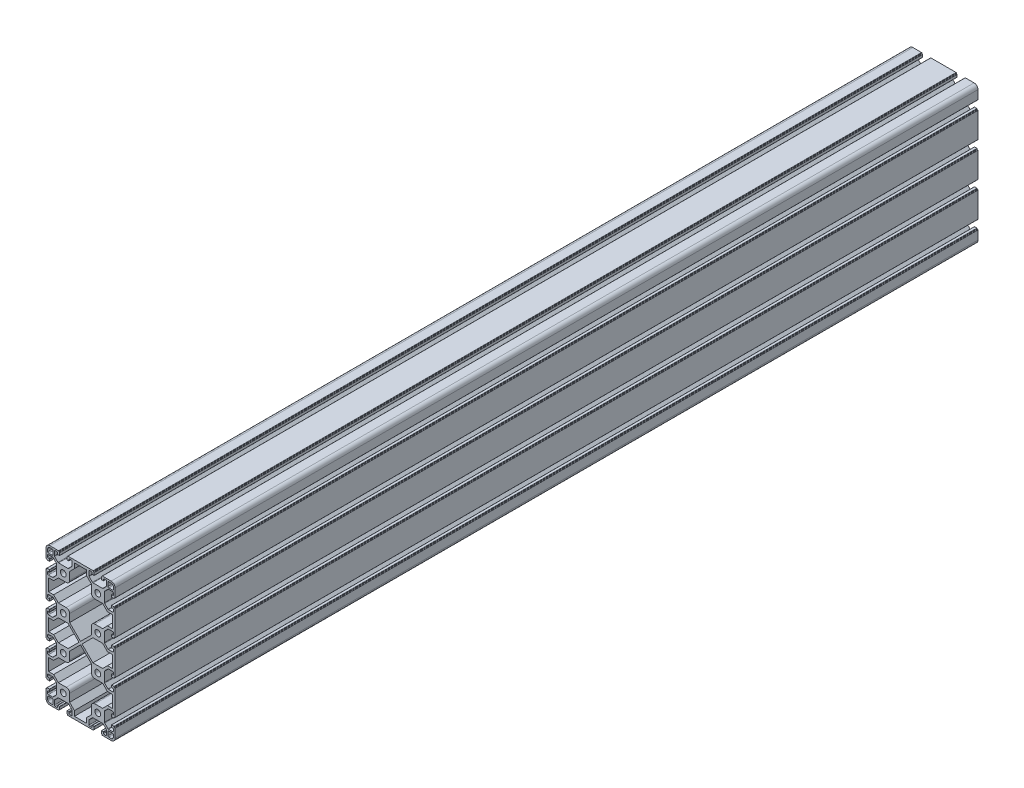
from build123d import *

# Parameters (mm, degrees)
SKETCH_1_R      = 3.4
EXTRUDE_1_DEPTH = 1000


with BuildPart() as part:
    # Эскиз1 → Бобышка-Вытянуть1 (new body)
    with BuildSketch(Plane.XY):
        with BuildLine():
            Line((-20, 10.25), (-20, 15.5))
            ThreePointArc((-20, 15.5), (-18.681980515, 18.681980515), (-15.5, 20))
            Line((-15.5, 20), (-10.25, 20))
            Line((-10.25, 20), (-5.4, 20))
            ThreePointArc((-5.4, 20), (-5.187867966, 19.912132034), (-5.1, 19.7))
            Line((-5.1, 19.7), (-5.1, 19.3))
            ThreePointArc((-5.1, 19.3), (-5.012132034, 19.087867966), (-4.8, 19))
            Line((-4.8, 19), (-4.4, 19))
            ThreePointArc((-4.4, 19), (-4.187867966, 18.912132034), (-4.1, 18.7))
            Line((-4.1, 18.7), (-4.1, 16))
            ThreePointArc((-4.1, 16), (-4.187867966, 15.787867966), (-4.4, 15.7))
            Line((-4.4, 15.7), (-6.3, 15.7))
            ThreePointArc((-6.3, 15.7), (-6.512132034, 15.787867966), (-6.6, 16))
            Line((-6.6, 16), (-6.6, 17.2))
            ThreePointArc((-6.6, 17.2), (-6.892893219, 17.907106781), (-7.6, 18.2))
            Line((-7.6, 18.2), (-9.25, 18.2))
            ThreePointArc((-9.25, 18.2), (-9.957106781, 17.907106781), (-10.25, 17.2))
            Line((-10.25, 17.2), (-10.25, 12.464213562))
            ThreePointArc((-10.25, 12.464213562), (-10.173879533, 12.08153013), (-9.957106781, 11.757106781))
            Line((-9.957106781, 11.757106781), (-6.192893219, 7.992893219))
            ThreePointArc((-6.192893219, 7.992893219), (-5.86846987, 7.776120467), (-5.485786438, 7.7))
            Line((-5.485786438, 7.7), (5.485786438, 7.7))
            ThreePointArc((5.485786438, 7.7), (5.86846987, 7.776120467), (6.192893219, 7.992893219))
            Line((6.192893219, 7.992893219), (9.957106781, 11.757106781))
            ThreePointArc((9.957106781, 11.757106781), (10.173879533, 12.08153013), (10.25, 12.464213562))
            Line((10.25, 12.464213562), (10.25, 17.2))
            ThreePointArc((10.25, 17.2), (9.957106781, 17.907106781), (9.25, 18.2))
            Line((9.25, 18.2), (7.6, 18.2))
            ThreePointArc((7.6, 18.2), (6.892893219, 17.907106781), (6.6, 17.2))
            Line((6.6, 17.2), (6.6, 16))
            ThreePointArc((6.6, 16), (6.512132034, 15.787867966), (6.3, 15.7))
            Line((6.3, 15.7), (4.4, 15.7))
            ThreePointArc((4.4, 15.7), (4.187867966, 15.787867966), (4.1, 16))
            Line((4.1, 16), (4.1, 18.7))
            ThreePointArc((4.1, 18.7), (4.187867966, 18.912132034), (4.4, 19))
            Line((4.4, 19), (4.8, 19))
            ThreePointArc((4.8, 19), (5.012132034, 19.087867966), (5.1, 19.3))
            Line((5.1, 19.3), (5.1, 19.7))
            ThreePointArc((5.1, 19.7), (5.187867966, 19.912132034), (5.4, 20))
            Line((5.4, 20), (10.25, 20))
            Line((10.25, 20), (29.75, 20))
            Line((29.75, 20), (34.6, 20))
            ThreePointArc((34.6, 20), (34.812132034, 19.912132034), (34.9, 19.7))
            Line((34.9, 19.7), (34.9, 19.3))
            ThreePointArc((34.9, 19.3), (34.987867966, 19.087867966), (35.2, 19))
            Line((35.2, 19), (35.6, 19))
            ThreePointArc((35.6, 19), (35.812132034, 18.912132034), (35.9, 18.7))
            Line((35.9, 18.7), (35.9, 16))
            ThreePointArc((35.9, 16), (35.812132034, 15.787867966), (35.6, 15.7))
            Line((35.6, 15.7), (33.7, 15.7))
            ThreePointArc((33.7, 15.7), (33.487867966, 15.787867966), (33.4, 16))
            Line((33.4, 16), (33.4, 17.2))
            ThreePointArc((33.4, 17.2), (33.107106781, 17.907106781), (32.4, 18.2))
            Line((32.4, 18.2), (30.75, 18.2))
            ThreePointArc((30.75, 18.2), (30.042893219, 17.907106781), (29.75, 17.2))
            Line((29.75, 17.2), (29.75, 12.464213562))
            ThreePointArc((29.75, 12.464213562), (29.826120467, 12.08153013), (30.042893219, 11.757106781))
            Line((30.042893219, 11.757106781), (33.807106781, 7.992893219))
            ThreePointArc((33.807106781, 7.992893219), (34.13153013, 7.776120467), (34.514213562, 7.7))
            Line((34.514213562, 7.7), (45.485786438, 7.7))
            ThreePointArc((45.485786438, 7.7), (45.86846987, 7.776120467), (46.192893219, 7.992893219))
            Line((46.192893219, 7.992893219), (49.957106781, 11.757106781))
            ThreePointArc((49.957106781, 11.757106781), (50.173879533, 12.08153013), (50.25, 12.464213562))
            Line((50.25, 12.464213562), (50.25, 17.2))
            ThreePointArc((50.25, 17.2), (49.957106781, 17.907106781), (49.25, 18.2))
            Line((49.25, 18.2), (47.6, 18.2))
            ThreePointArc((47.6, 18.2), (46.892893219, 17.907106781), (46.6, 17.2))
            Line((46.6, 17.2), (46.6, 16))
            ThreePointArc((46.6, 16), (46.512132034, 15.787867966), (46.3, 15.7))
            Line((46.3, 15.7), (44.4, 15.7))
            ThreePointArc((44.4, 15.7), (44.187867966, 15.787867966), (44.1, 16))
            Line((44.1, 16), (44.1, 18.7))
            ThreePointArc((44.1, 18.7), (44.187867966, 18.912132034), (44.4, 19))
            Line((44.4, 19), (44.8, 19))
            ThreePointArc((44.8, 19), (45.012132034, 19.087867966), (45.1, 19.3))
            Line((45.1, 19.3), (45.1, 19.7))
            ThreePointArc((45.1, 19.7), (45.187867966, 19.912132034), (45.4, 20))
            Line((45.4, 20), (50.25, 20))
            Line((50.25, 20), (55.5, 20))
            ThreePointArc((55.5, 20), (58.681980515, 18.681980515), (60, 15.5))
            Line((60, 15.5), (60, 10.25))
            Line((60, 10.25), (60, 5.4))
            ThreePointArc((60, 5.4), (59.912132034, 5.187867966), (59.7, 5.1))
            Line((59.7, 5.1), (59.3, 5.1))
            ThreePointArc((59.3, 5.1), (59.087867966, 5.012132034), (59, 4.8))
            Line((59, 4.8), (59, 4.4))
            ThreePointArc((59, 4.4), (58.912132034, 4.187867966), (58.7, 4.1))
            Line((58.7, 4.1), (56, 4.1))
            ThreePointArc((56, 4.1), (55.787867966, 4.187867966), (55.7, 4.4))
            Line((55.7, 4.4), (55.7, 6.3))
            ThreePointArc((55.7, 6.3), (55.787867966, 6.512132034), (56, 6.6))
            Line((56, 6.6), (57.2, 6.6))
            ThreePointArc((57.2, 6.6), (57.907106781, 6.892893219), (58.2, 7.6))
            Line((58.2, 7.6), (58.2, 9.25))
            ThreePointArc((58.2, 9.25), (57.907106781, 9.957106781), (57.2, 10.25))
            Line((57.2, 10.25), (52.464213562, 10.25))
            ThreePointArc((52.464213562, 10.25), (52.08153013, 10.173879533), (51.757106781, 9.957106781))
            Line((51.757106781, 9.957106781), (47.992893219, 6.192893219))
            ThreePointArc((47.992893219, 6.192893219), (47.776120467, 5.86846987), (47.7, 5.485786438))
            Line((47.7, 5.485786438), (47.7, -5.485786438))
            ThreePointArc((47.7, -5.485786438), (47.776120467, -5.86846987), (47.992893219, -6.192893219))
            Line((47.992893219, -6.192893219), (51.757106781, -9.957106781))
            ThreePointArc((51.757106781, -9.957106781), (52.08153013, -10.173879533), (52.464213562, -10.25))
            Line((52.464213562, -10.25), (57.2, -10.25))
            ThreePointArc((57.2, -10.25), (57.907106781, -9.957106781), (58.2, -9.25))
            Line((58.2, -9.25), (58.2, -7.6))
            ThreePointArc((58.2, -7.6), (57.907106781, -6.892893219), (57.2, -6.6))
            Line((57.2, -6.6), (56, -6.6))
            ThreePointArc((56, -6.6), (55.787867966, -6.512132034), (55.7, -6.3))
            Line((55.7, -6.3), (55.7, -4.4))
            ThreePointArc((55.7, -4.4), (55.787867966, -4.187867966), (56, -4.1))
            Line((56, -4.1), (58.7, -4.1))
            ThreePointArc((58.7, -4.1), (58.912132034, -4.187867966), (59, -4.4))
            Line((59, -4.4), (59, -4.8))
            ThreePointArc((59, -4.8), (59.087867966, -5.012132034), (59.3, -5.1))
            Line((59.3, -5.1), (59.7, -5.1))
            ThreePointArc((59.7, -5.1), (59.912132034, -5.187867966), (60, -5.4))
            Line((60, -5.4), (60, -10.25))
            Line((60, -10.25), (60, -29.75))
            Line((60, -29.75), (60, -34.6))
            ThreePointArc((60, -34.6), (59.912132034, -34.812132034), (59.7, -34.9))
            Line((59.7, -34.9), (59.3, -34.9))
            ThreePointArc((59.3, -34.9), (59.087867966, -34.987867966), (59, -35.2))
            Line((59, -35.2), (59, -35.6))
            ThreePointArc((59, -35.6), (58.912132034, -35.812132034), (58.7, -35.9))
            Line((58.7, -35.9), (56, -35.9))
            ThreePointArc((56, -35.9), (55.787867966, -35.812132034), (55.7, -35.6))
            Line((55.7, -35.6), (55.7, -33.7))
            ThreePointArc((55.7, -33.7), (55.787867966, -33.487867966), (56, -33.4))
            Line((56, -33.4), (57.2, -33.4))
            ThreePointArc((57.2, -33.4), (57.907106781, -33.107106781), (58.2, -32.4))
            Line((58.2, -32.4), (58.2, -30.75))
            ThreePointArc((58.2, -30.75), (57.907106781, -30.042893219), (57.2, -29.75))
            Line((57.2, -29.75), (52.464213562, -29.75))
            ThreePointArc((52.464213562, -29.75), (52.08153013, -29.826120467), (51.757106781, -30.042893219))
            Line((51.757106781, -30.042893219), (47.992893219, -33.807106781))
            ThreePointArc((47.992893219, -33.807106781), (47.776120467, -34.13153013), (47.7, -34.514213562))
            Line((47.7, -34.514213562), (47.7, -45.485786438))
            ThreePointArc((47.7, -45.485786438), (47.776120467, -45.86846987), (47.992893219, -46.192893219))
            Line((47.992893219, -46.192893219), (51.757106781, -49.957106781))
            ThreePointArc((51.757106781, -49.957106781), (52.08153013, -50.173879533), (52.464213562, -50.25))
            Line((52.464213562, -50.25), (57.2, -50.25))
            ThreePointArc((57.2, -50.25), (57.907106781, -49.957106781), (58.2, -49.25))
            Line((58.2, -49.25), (58.2, -47.6))
            ThreePointArc((58.2, -47.6), (57.907106781, -46.892893219), (57.2, -46.6))
            Line((57.2, -46.6), (56, -46.6))
            ThreePointArc((56, -46.6), (55.787867966, -46.512132034), (55.7, -46.3))
            Line((55.7, -46.3), (55.7, -44.4))
            ThreePointArc((55.7, -44.4), (55.787867966, -44.187867966), (56, -44.1))
            Line((56, -44.1), (58.7, -44.1))
            ThreePointArc((58.7, -44.1), (58.912132034, -44.187867966), (59, -44.4))
            Line((59, -44.4), (59, -44.8))
            ThreePointArc((59, -44.8), (59.087867966, -45.012132034), (59.3, -45.1))
            Line((59.3, -45.1), (59.7, -45.1))
            ThreePointArc((59.7, -45.1), (59.912132034, -45.187867966), (60, -45.4))
            Line((60, -45.4), (60, -50.25))
            Line((60, -50.25), (60, -69.75))
            Line((60, -69.75), (60, -74.6))
            ThreePointArc((60, -74.6), (59.912132034, -74.812132034), (59.7, -74.9))
            Line((59.7, -74.9), (59.3, -74.9))
            ThreePointArc((59.3, -74.9), (59.087867966, -74.987867966), (59, -75.2))
            Line((59, -75.2), (59, -75.6))
            ThreePointArc((59, -75.6), (58.912132034, -75.812132034), (58.7, -75.9))
            Line((58.7, -75.9), (56, -75.9))
            ThreePointArc((56, -75.9), (55.787867966, -75.812132034), (55.7, -75.6))
            Line((55.7, -75.6), (55.7, -73.7))
            ThreePointArc((55.7, -73.7), (55.787867966, -73.487867966), (56, -73.4))
            Line((56, -73.4), (57.2, -73.4))
            ThreePointArc((57.2, -73.4), (57.907106781, -73.107106781), (58.2, -72.4))
            Line((58.2, -72.4), (58.2, -70.75))
            ThreePointArc((58.2, -70.75), (57.907106781, -70.042893219), (57.2, -69.75))
            Line((57.2, -69.75), (52.464213562, -69.75))
            ThreePointArc((52.464213562, -69.75), (52.08153013, -69.826120467), (51.757106781, -70.042893219))
            Line((51.757106781, -70.042893219), (47.992893219, -73.807106781))
            ThreePointArc((47.992893219, -73.807106781), (47.776120467, -74.13153013), (47.7, -74.514213562))
            Line((47.7, -74.514213562), (47.7, -85.485786438))
            ThreePointArc((47.7, -85.485786438), (47.776120467, -85.86846987), (47.992893219, -86.192893219))
            Line((47.992893219, -86.192893219), (51.757106781, -89.957106781))
            ThreePointArc((51.757106781, -89.957106781), (52.08153013, -90.173879533), (52.464213562, -90.25))
            Line((52.464213562, -90.25), (57.2, -90.25))
            ThreePointArc((57.2, -90.25), (57.907106781, -89.957106781), (58.2, -89.25))
            Line((58.2, -89.25), (58.2, -87.6))
            ThreePointArc((58.2, -87.6), (57.907106781, -86.892893219), (57.2, -86.6))
            Line((57.2, -86.6), (56, -86.6))
            ThreePointArc((56, -86.6), (55.787867966, -86.512132034), (55.7, -86.3))
            Line((55.7, -86.3), (55.7, -84.4))
            ThreePointArc((55.7, -84.4), (55.787867966, -84.187867966), (56, -84.1))
            Line((56, -84.1), (58.7, -84.1))
            ThreePointArc((58.7, -84.1), (58.912132034, -84.187867966), (59, -84.4))
            Line((59, -84.4), (59, -84.8))
            ThreePointArc((59, -84.8), (59.087867966, -85.012132034), (59.3, -85.1))
            Line((59.3, -85.1), (59.7, -85.1))
            ThreePointArc((59.7, -85.1), (59.912132034, -85.187867966), (60, -85.4))
            Line((60, -85.4), (60, -90.25))
            Line((60, -90.25), (60, -109.75))
            Line((60, -109.75), (60, -114.6))
            ThreePointArc((60, -114.6), (59.912132034, -114.812132034), (59.7, -114.9))
            Line((59.7, -114.9), (59.3, -114.9))
            ThreePointArc((59.3, -114.9), (59.087867966, -114.987867966), (59, -115.2))
            Line((59, -115.2), (59, -115.6))
            ThreePointArc((59, -115.6), (58.912132034, -115.812132034), (58.7, -115.9))
            Line((58.7, -115.9), (56, -115.9))
            ThreePointArc((56, -115.9), (55.787867966, -115.812132034), (55.7, -115.6))
            Line((55.7, -115.6), (55.7, -113.7))
            ThreePointArc((55.7, -113.7), (55.787867966, -113.487867966), (56, -113.4))
            Line((56, -113.4), (57.2, -113.4))
            ThreePointArc((57.2, -113.4), (57.907106781, -113.107106781), (58.2, -112.4))
            Line((58.2, -112.4), (58.2, -110.75))
            ThreePointArc((58.2, -110.75), (57.907106781, -110.042893219), (57.2, -109.75))
            Line((57.2, -109.75), (52.464213562, -109.75))
            ThreePointArc((52.464213562, -109.75), (52.08153013, -109.826120467), (51.757106781, -110.042893219))
            Line((51.757106781, -110.042893219), (47.992893219, -113.807106781))
            ThreePointArc((47.992893219, -113.807106781), (47.776120467, -114.13153013), (47.7, -114.514213562))
            Line((47.7, -114.514213562), (47.7, -125.485786438))
            ThreePointArc((47.7, -125.485786438), (47.776120467, -125.86846987), (47.992893219, -126.192893219))
            Line((47.992893219, -126.192893219), (51.757106781, -129.957106781))
            ThreePointArc((51.757106781, -129.957106781), (52.08153013, -130.173879533), (52.464213562, -130.25))
            Line((52.464213562, -130.25), (57.2, -130.25))
            ThreePointArc((57.2, -130.25), (57.907106781, -129.957106781), (58.2, -129.25))
            Line((58.2, -129.25), (58.2, -127.6))
            ThreePointArc((58.2, -127.6), (57.907106781, -126.892893219), (57.2, -126.6))
            Line((57.2, -126.6), (56, -126.6))
            ThreePointArc((56, -126.6), (55.787867966, -126.512132034), (55.7, -126.3))
            Line((55.7, -126.3), (55.7, -124.4))
            ThreePointArc((55.7, -124.4), (55.787867966, -124.187867966), (56, -124.1))
            Line((56, -124.1), (58.7, -124.1))
            ThreePointArc((58.7, -124.1), (58.912132034, -124.187867966), (59, -124.4))
            Line((59, -124.4), (59, -124.8))
            ThreePointArc((59, -124.8), (59.087867966, -125.012132034), (59.3, -125.1))
            Line((59.3, -125.1), (59.7, -125.1))
            ThreePointArc((59.7, -125.1), (59.912132034, -125.187867966), (60, -125.4))
            Line((60, -125.4), (60, -130.25))
            Line((60, -130.25), (60, -135.5))
            ThreePointArc((60, -135.5), (58.681980515, -138.681980515), (55.5, -140))
            Line((55.5, -140), (50.25, -140))
            Line((50.25, -140), (45.4, -140))
            ThreePointArc((45.4, -140), (45.187867966, -139.912132034), (45.1, -139.7))
            Line((45.1, -139.7), (45.1, -139.3))
            ThreePointArc((45.1, -139.3), (45.012132034, -139.087867966), (44.8, -139))
            Line((44.8, -139), (44.4, -139))
            ThreePointArc((44.4, -139), (44.187867966, -138.912132034), (44.1, -138.7))
            Line((44.1, -138.7), (44.1, -136))
            ThreePointArc((44.1, -136), (44.187867966, -135.787867966), (44.4, -135.7))
            Line((44.4, -135.7), (46.3, -135.7))
            ThreePointArc((46.3, -135.7), (46.512132034, -135.787867966), (46.6, -136))
            Line((46.6, -136), (46.6, -137.2))
            ThreePointArc((46.6, -137.2), (46.892893219, -137.907106781), (47.6, -138.2))
            Line((47.6, -138.2), (49.25, -138.2))
            ThreePointArc((49.25, -138.2), (49.957106781, -137.907106781), (50.25, -137.2))
            Line((50.25, -137.2), (50.25, -132.464213562))
            ThreePointArc((50.25, -132.464213562), (50.173879533, -132.08153013), (49.957106781, -131.757106781))
            Line((49.957106781, -131.757106781), (46.192893219, -127.992893219))
            ThreePointArc((46.192893219, -127.992893219), (45.86846987, -127.776120467), (45.485786438, -127.7))
            Line((45.485786438, -127.7), (34.514213562, -127.7))
            ThreePointArc((34.514213562, -127.7), (34.13153013, -127.776120467), (33.807106781, -127.992893219))
            Line((33.807106781, -127.992893219), (30.042893219, -131.757106781))
            ThreePointArc((30.042893219, -131.757106781), (29.826120467, -132.08153013), (29.75, -132.464213562))
            Line((29.75, -132.464213562), (29.75, -137.2))
            ThreePointArc((29.75, -137.2), (30.042893219, -137.907106781), (30.75, -138.2))
            Line((30.75, -138.2), (32.4, -138.2))
            ThreePointArc((32.4, -138.2), (33.107106781, -137.907106781), (33.4, -137.2))
            Line((33.4, -137.2), (33.4, -136))
            ThreePointArc((33.4, -136), (33.487867966, -135.787867966), (33.7, -135.7))
            Line((33.7, -135.7), (35.6, -135.7))
            ThreePointArc((35.6, -135.7), (35.812132034, -135.787867966), (35.9, -136))
            Line((35.9, -136), (35.9, -138.7))
            ThreePointArc((35.9, -138.7), (35.812132034, -138.912132034), (35.6, -139))
            Line((35.6, -139), (35.2, -139))
            ThreePointArc((35.2, -139), (34.987867966, -139.087867966), (34.9, -139.3))
            Line((34.9, -139.3), (34.9, -139.7))
            ThreePointArc((34.9, -139.7), (34.812132034, -139.912132034), (34.6, -140))
            Line((34.6, -140), (29.75, -140))
            Line((29.75, -140), (10.25, -140))
            Line((10.25, -140), (5.4, -140))
            ThreePointArc((5.4, -140), (5.187867966, -139.912132034), (5.1, -139.7))
            Line((5.1, -139.7), (5.1, -139.3))
            ThreePointArc((5.1, -139.3), (5.012132034, -139.087867966), (4.8, -139))
            Line((4.8, -139), (4.4, -139))
            ThreePointArc((4.4, -139), (4.187867966, -138.912132034), (4.1, -138.7))
            Line((4.1, -138.7), (4.1, -136))
            ThreePointArc((4.1, -136), (4.187867966, -135.787867966), (4.4, -135.7))
            Line((4.4, -135.7), (6.3, -135.7))
            ThreePointArc((6.3, -135.7), (6.512132034, -135.787867966), (6.6, -136))
            Line((6.6, -136), (6.6, -137.2))
            ThreePointArc((6.6, -137.2), (6.892893219, -137.907106781), (7.6, -138.2))
            Line((7.6, -138.2), (9.25, -138.2))
            ThreePointArc((9.25, -138.2), (9.957106781, -137.907106781), (10.25, -137.2))
            Line((10.25, -137.2), (10.25, -132.464213562))
            ThreePointArc((10.25, -132.464213562), (10.173879533, -132.08153013), (9.957106781, -131.757106781))
            Line((9.957106781, -131.757106781), (6.192893219, -127.992893219))
            ThreePointArc((6.192893219, -127.992893219), (5.86846987, -127.776120467), (5.485786438, -127.7))
            Line((5.485786438, -127.7), (-5.485786438, -127.7))
            ThreePointArc((-5.485786438, -127.7), (-5.86846987, -127.776120467), (-6.192893219, -127.992893219))
            Line((-6.192893219, -127.992893219), (-9.957106781, -131.757106781))
            ThreePointArc((-9.957106781, -131.757106781), (-10.173879533, -132.08153013), (-10.25, -132.464213562))
            Line((-10.25, -132.464213562), (-10.25, -137.2))
            ThreePointArc((-10.25, -137.2), (-9.957106781, -137.907106781), (-9.25, -138.2))
            Line((-9.25, -138.2), (-7.6, -138.2))
            ThreePointArc((-7.6, -138.2), (-6.892893219, -137.907106781), (-6.6, -137.2))
            Line((-6.6, -137.2), (-6.6, -136))
            ThreePointArc((-6.6, -136), (-6.512132034, -135.787867966), (-6.3, -135.7))
            Line((-6.3, -135.7), (-4.4, -135.7))
            ThreePointArc((-4.4, -135.7), (-4.187867966, -135.787867966), (-4.1, -136))
            Line((-4.1, -136), (-4.1, -138.7))
            ThreePointArc((-4.1, -138.7), (-4.187867966, -138.912132034), (-4.4, -139))
            Line((-4.4, -139), (-4.8, -139))
            ThreePointArc((-4.8, -139), (-5.012132034, -139.087867966), (-5.1, -139.3))
            Line((-5.1, -139.3), (-5.1, -139.7))
            ThreePointArc((-5.1, -139.7), (-5.187867966, -139.912132034), (-5.4, -140))
            Line((-5.4, -140), (-10.25, -140))
            Line((-10.25, -140), (-15.5, -140))
            ThreePointArc((-15.5, -140), (-18.681980515, -138.681980515), (-20, -135.5))
            Line((-20, -135.5), (-20, -130.25))
            Line((-20, -130.25), (-20, -125.4))
            ThreePointArc((-20, -125.4), (-19.912132034, -125.187867966), (-19.7, -125.1))
            Line((-19.7, -125.1), (-19.3, -125.1))
            ThreePointArc((-19.3, -125.1), (-19.087867966, -125.012132034), (-19, -124.8))
            Line((-19, -124.8), (-19, -124.4))
            ThreePointArc((-19, -124.4), (-18.912132034, -124.187867966), (-18.7, -124.1))
            Line((-18.7, -124.1), (-16, -124.1))
            ThreePointArc((-16, -124.1), (-15.787867966, -124.187867966), (-15.7, -124.4))
            Line((-15.7, -124.4), (-15.7, -126.3))
            ThreePointArc((-15.7, -126.3), (-15.787867966, -126.512132034), (-16, -126.6))
            Line((-16, -126.6), (-17.2, -126.6))
            ThreePointArc((-17.2, -126.6), (-17.907106781, -126.892893219), (-18.2, -127.6))
            Line((-18.2, -127.6), (-18.2, -129.25))
            ThreePointArc((-18.2, -129.25), (-17.907106781, -129.957106781), (-17.2, -130.25))
            Line((-17.2, -130.25), (-12.464213562, -130.25))
            ThreePointArc((-12.464213562, -130.25), (-12.08153013, -130.173879533), (-11.757106781, -129.957106781))
            Line((-11.757106781, -129.957106781), (-7.992893219, -126.192893219))
            ThreePointArc((-7.992893219, -126.192893219), (-7.776120467, -125.86846987), (-7.7, -125.485786438))
            Line((-7.7, -125.485786438), (-7.7, -114.514213562))
            ThreePointArc((-7.7, -114.514213562), (-7.776120467, -114.13153013), (-7.992893219, -113.807106781))
            Line((-7.992893219, -113.807106781), (-11.757106781, -110.042893219))
            ThreePointArc((-11.757106781, -110.042893219), (-12.08153013, -109.826120467), (-12.464213562, -109.75))
            Line((-12.464213562, -109.75), (-17.2, -109.75))
            ThreePointArc((-17.2, -109.75), (-17.907106781, -110.042893219), (-18.2, -110.75))
            Line((-18.2, -110.75), (-18.2, -112.4))
            ThreePointArc((-18.2, -112.4), (-17.907106781, -113.107106781), (-17.2, -113.4))
            Line((-17.2, -113.4), (-16, -113.4))
            ThreePointArc((-16, -113.4), (-15.787867966, -113.487867966), (-15.7, -113.7))
            Line((-15.7, -113.7), (-15.7, -115.6))
            ThreePointArc((-15.7, -115.6), (-15.787867966, -115.812132034), (-16, -115.9))
            Line((-16, -115.9), (-18.7, -115.9))
            ThreePointArc((-18.7, -115.9), (-18.912132034, -115.812132034), (-19, -115.6))
            Line((-19, -115.6), (-19, -115.2))
            ThreePointArc((-19, -115.2), (-19.087867966, -114.987867966), (-19.3, -114.9))
            Line((-19.3, -114.9), (-19.7, -114.9))
            ThreePointArc((-19.7, -114.9), (-19.912132034, -114.812132034), (-20, -114.6))
            Line((-20, -114.6), (-20, -109.75))
            Line((-20, -109.75), (-20, -90.25))
            Line((-20, -90.25), (-20, -85.4))
            ThreePointArc((-20, -85.4), (-19.912132034, -85.187867966), (-19.7, -85.1))
            Line((-19.7, -85.1), (-19.3, -85.1))
            ThreePointArc((-19.3, -85.1), (-19.087867966, -85.012132034), (-19, -84.8))
            Line((-19, -84.8), (-19, -84.4))
            ThreePointArc((-19, -84.4), (-18.912132034, -84.187867966), (-18.7, -84.1))
            Line((-18.7, -84.1), (-16, -84.1))
            ThreePointArc((-16, -84.1), (-15.787867966, -84.187867966), (-15.7, -84.4))
            Line((-15.7, -84.4), (-15.7, -86.3))
            ThreePointArc((-15.7, -86.3), (-15.787867966, -86.512132034), (-16, -86.6))
            Line((-16, -86.6), (-17.2, -86.6))
            ThreePointArc((-17.2, -86.6), (-17.907106781, -86.892893219), (-18.2, -87.6))
            Line((-18.2, -87.6), (-18.2, -89.25))
            ThreePointArc((-18.2, -89.25), (-17.907106781, -89.957106781), (-17.2, -90.25))
            Line((-17.2, -90.25), (-12.464213562, -90.25))
            ThreePointArc((-12.464213562, -90.25), (-12.08153013, -90.173879533), (-11.757106781, -89.957106781))
            Line((-11.757106781, -89.957106781), (-7.992893219, -86.192893219))
            ThreePointArc((-7.992893219, -86.192893219), (-7.776120467, -85.86846987), (-7.7, -85.485786438))
            Line((-7.7, -85.485786438), (-7.7, -74.514213562))
            ThreePointArc((-7.7, -74.514213562), (-7.776120467, -74.13153013), (-7.992893219, -73.807106781))
            Line((-7.992893219, -73.807106781), (-11.757106781, -70.042893219))
            ThreePointArc((-11.757106781, -70.042893219), (-12.08153013, -69.826120467), (-12.464213562, -69.75))
            Line((-12.464213562, -69.75), (-17.2, -69.75))
            ThreePointArc((-17.2, -69.75), (-17.907106781, -70.042893219), (-18.2, -70.75))
            Line((-18.2, -70.75), (-18.2, -72.4))
            ThreePointArc((-18.2, -72.4), (-17.907106781, -73.107106781), (-17.2, -73.4))
            Line((-17.2, -73.4), (-16, -73.4))
            ThreePointArc((-16, -73.4), (-15.787867966, -73.487867966), (-15.7, -73.7))
            Line((-15.7, -73.7), (-15.7, -75.6))
            ThreePointArc((-15.7, -75.6), (-15.787867966, -75.812132034), (-16, -75.9))
            Line((-16, -75.9), (-18.7, -75.9))
            ThreePointArc((-18.7, -75.9), (-18.912132034, -75.812132034), (-19, -75.6))
            Line((-19, -75.6), (-19, -75.2))
            ThreePointArc((-19, -75.2), (-19.087867966, -74.987867966), (-19.3, -74.9))
            Line((-19.3, -74.9), (-19.7, -74.9))
            ThreePointArc((-19.7, -74.9), (-19.912132034, -74.812132034), (-20, -74.6))
            Line((-20, -74.6), (-20, -69.75))
            Line((-20, -69.75), (-20, -50.25))
            Line((-20, -50.25), (-20, -45.4))
            ThreePointArc((-20, -45.4), (-19.912132034, -45.187867966), (-19.7, -45.1))
            Line((-19.7, -45.1), (-19.3, -45.1))
            ThreePointArc((-19.3, -45.1), (-19.087867966, -45.012132034), (-19, -44.8))
            Line((-19, -44.8), (-19, -44.4))
            ThreePointArc((-19, -44.4), (-18.912132034, -44.187867966), (-18.7, -44.1))
            Line((-18.7, -44.1), (-16, -44.1))
            ThreePointArc((-16, -44.1), (-15.787867966, -44.187867966), (-15.7, -44.4))
            Line((-15.7, -44.4), (-15.7, -46.3))
            ThreePointArc((-15.7, -46.3), (-15.787867966, -46.512132034), (-16, -46.6))
            Line((-16, -46.6), (-17.2, -46.6))
            ThreePointArc((-17.2, -46.6), (-17.907106781, -46.892893219), (-18.2, -47.6))
            Line((-18.2, -47.6), (-18.2, -49.25))
            ThreePointArc((-18.2, -49.25), (-17.907106781, -49.957106781), (-17.2, -50.25))
            Line((-17.2, -50.25), (-12.464213562, -50.25))
            ThreePointArc((-12.464213562, -50.25), (-12.08153013, -50.173879533), (-11.757106781, -49.957106781))
            Line((-11.757106781, -49.957106781), (-7.992893219, -46.192893219))
            ThreePointArc((-7.992893219, -46.192893219), (-7.776120467, -45.86846987), (-7.7, -45.485786438))
            Line((-7.7, -45.485786438), (-7.7, -34.514213562))
            ThreePointArc((-7.7, -34.514213562), (-7.776120467, -34.13153013), (-7.992893219, -33.807106781))
            Line((-7.992893219, -33.807106781), (-11.757106781, -30.042893219))
            ThreePointArc((-11.757106781, -30.042893219), (-12.08153013, -29.826120467), (-12.464213562, -29.75))
            Line((-12.464213562, -29.75), (-17.2, -29.75))
            ThreePointArc((-17.2, -29.75), (-17.907106781, -30.042893219), (-18.2, -30.75))
            Line((-18.2, -30.75), (-18.2, -32.4))
            ThreePointArc((-18.2, -32.4), (-17.907106781, -33.107106781), (-17.2, -33.4))
            Line((-17.2, -33.4), (-16, -33.4))
            ThreePointArc((-16, -33.4), (-15.787867966, -33.487867966), (-15.7, -33.7))
            Line((-15.7, -33.7), (-15.7, -35.6))
            ThreePointArc((-15.7, -35.6), (-15.787867966, -35.812132034), (-16, -35.9))
            Line((-16, -35.9), (-18.7, -35.9))
            ThreePointArc((-18.7, -35.9), (-18.912132034, -35.812132034), (-19, -35.6))
            Line((-19, -35.6), (-19, -35.2))
            ThreePointArc((-19, -35.2), (-19.087867966, -34.987867966), (-19.3, -34.9))
            Line((-19.3, -34.9), (-19.7, -34.9))
            ThreePointArc((-19.7, -34.9), (-19.912132034, -34.812132034), (-20, -34.6))
            Line((-20, -34.6), (-20, -29.75))
            Line((-20, -29.75), (-20, -10.25))
            Line((-20, -10.25), (-20, -5.4))
            ThreePointArc((-20, -5.4), (-19.912132034, -5.187867966), (-19.7, -5.1))
            Line((-19.7, -5.1), (-19.3, -5.1))
            ThreePointArc((-19.3, -5.1), (-19.087867966, -5.012132034), (-19, -4.8))
            Line((-19, -4.8), (-19, -4.4))
            ThreePointArc((-19, -4.4), (-18.912132034, -4.187867966), (-18.7, -4.1))
            Line((-18.7, -4.1), (-16, -4.1))
            ThreePointArc((-16, -4.1), (-15.787867966, -4.187867966), (-15.7, -4.4))
            Line((-15.7, -4.4), (-15.7, -6.3))
            ThreePointArc((-15.7, -6.3), (-15.787867966, -6.512132034), (-16, -6.6))
            Line((-16, -6.6), (-17.2, -6.6))
            ThreePointArc((-17.2, -6.6), (-17.907106781, -6.892893219), (-18.2, -7.6))
            Line((-18.2, -7.6), (-18.2, -9.25))
            ThreePointArc((-18.2, -9.25), (-17.907106781, -9.957106781), (-17.2, -10.25))
            Line((-17.2, -10.25), (-12.464213562, -10.25))
            ThreePointArc((-12.464213562, -10.25), (-12.08153013, -10.173879533), (-11.757106781, -9.957106781))
            Line((-11.757106781, -9.957106781), (-7.992893219, -6.192893219))
            ThreePointArc((-7.992893219, -6.192893219), (-7.776120467, -5.86846987), (-7.7, -5.485786438))
            Line((-7.7, -5.485786438), (-7.7, 5.485786438))
            ThreePointArc((-7.7, 5.485786438), (-7.776120467, 5.86846987), (-7.992893219, 6.192893219))
            Line((-7.992893219, 6.192893219), (-11.757106781, 9.957106781))
            ThreePointArc((-11.757106781, 9.957106781), (-12.08153013, 10.173879533), (-12.464213562, 10.25))
            Line((-12.464213562, 10.25), (-17.2, 10.25))
            ThreePointArc((-17.2, 10.25), (-17.907106781, 9.957106781), (-18.2, 9.25))
            Line((-18.2, 9.25), (-18.2, 7.6))
            ThreePointArc((-18.2, 7.6), (-17.907106781, 6.892893219), (-17.2, 6.6))
            Line((-17.2, 6.6), (-16, 6.6))
            ThreePointArc((-16, 6.6), (-15.787867966, 6.512132034), (-15.7, 6.3))
            Line((-15.7, 6.3), (-15.7, 4.4))
            ThreePointArc((-15.7, 4.4), (-15.787867966, 4.187867966), (-16, 4.1))
            Line((-16, 4.1), (-18.7, 4.1))
            ThreePointArc((-18.7, 4.1), (-18.912132034, 4.187867966), (-19, 4.4))
            Line((-19, 4.4), (-19, 4.8))
            ThreePointArc((-19, 4.8), (-19.087867966, 5.012132034), (-19.3, 5.1))
            Line((-19.3, 5.1), (-19.7, 5.1))
            ThreePointArc((-19.7, 5.1), (-19.912132034, 5.187867966), (-20, 5.4))
            Line((-20, 5.4), (-20, 10.25))
        make_face()
        Circle(SKETCH_1_R, mode=Mode.SUBTRACT)
        with Locations((40, 0)):
            Circle(SKETCH_1_R, mode=Mode.SUBTRACT)
        with Locations((40, -40)):
            Circle(SKETCH_1_R, mode=Mode.SUBTRACT)
        with Locations((0, -40)):
            Circle(SKETCH_1_R, mode=Mode.SUBTRACT)
        with Locations((40, -80)):
            Circle(SKETCH_1_R, mode=Mode.SUBTRACT)
        with Locations((0, -80)):
            Circle(SKETCH_1_R, mode=Mode.SUBTRACT)
        with Locations((40, -120)):
            Circle(SKETCH_1_R, mode=Mode.SUBTRACT)
        with Locations((0, -120)):
            Circle(SKETCH_1_R, mode=Mode.SUBTRACT)
        with BuildLine():
            Line((-12.8, 11.8), (-17, 11.8))
            ThreePointArc((-17, 11.8), (-17.707106781, 12.092893219), (-18, 12.8))
            Line((-18, 12.8), (-18, 15.5))
            ThreePointArc((-18, 15.5), (-17.267766953, 17.267766953), (-15.5, 18))
            Line((-15.5, 18), (-12.8, 18))
            ThreePointArc((-12.8, 18), (-12.092893219, 17.707106781), (-11.8, 17))
            Line((-11.8, 17), (-11.8, 12.8))
            ThreePointArc((-11.8, 12.8), (-12.092893219, 12.092893219), (-12.8, 11.8))
        make_face(mode=Mode.SUBTRACT)
        with BuildLine():
            Line((58, 12.8), (58, 15.5))
            ThreePointArc((58, 15.5), (57.267766953, 17.267766953), (55.5, 18))
            Line((55.5, 18), (52.8, 18))
            ThreePointArc((52.8, 18), (52.092893219, 17.707106781), (51.8, 17))
            Line((51.8, 17), (51.8, 12.8))
            ThreePointArc((51.8, 12.8), (52.092893219, 12.092893219), (52.8, 11.8))
            Line((52.8, 11.8), (57, 11.8))
            ThreePointArc((57, 11.8), (57.707106781, 12.092893219), (58, 12.8))
        make_face(mode=Mode.SUBTRACT)
        with BuildLine():
            Line((51.8, -132.8), (51.8, -137))
            ThreePointArc((51.8, -137), (52.092893219, -137.707106781), (52.8, -138))
            Line((52.8, -138), (55.5, -138))
            ThreePointArc((55.5, -138), (57.267766953, -137.267766953), (58, -135.5))
            Line((58, -135.5), (58, -132.8))
            ThreePointArc((58, -132.8), (57.707106781, -132.092893219), (57, -131.8))
            Line((57, -131.8), (52.8, -131.8))
            ThreePointArc((52.8, -131.8), (52.092893219, -132.092893219), (51.8, -132.8))
        make_face(mode=Mode.SUBTRACT)
        with BuildLine():
            Line((-12.8, -138), (-15.5, -138))
            ThreePointArc((-15.5, -138), (-17.267766953, -137.267766953), (-18, -135.5))
            Line((-18, -135.5), (-18, -132.8))
            ThreePointArc((-18, -132.8), (-17.707106781, -132.092893219), (-17, -131.8))
            Line((-17, -131.8), (-12.8, -131.8))
            ThreePointArc((-12.8, -131.8), (-12.092893219, -132.092893219), (-11.8, -132.8))
            Line((-11.8, -132.8), (-11.8, -137))
            ThreePointArc((-11.8, -137), (-12.092893219, -137.707106781), (-12.8, -138))
        make_face(mode=Mode.SUBTRACT)
        with BuildLine():
            Line((27.064466094, 17), (12.935533906, 17))
            Line((12.935533906, 17), (12.935533906, 11.2))
            Line((12.935533906, 11.2), (7.4, 5.664466094))
            Line((7.4, 5.664466094), (7.4, -3.4))
            ThreePointArc((7.4, -3.4), (6.228427125, -6.228427125), (3.4, -7.4))
            Line((3.4, -7.4), (-5.664466094, -7.4))
            Line((-5.664466094, -7.4), (-11.2, -12.935533906))
            Line((-11.2, -12.935533906), (-17, -12.935533906))
            Line((-17, -12.935533906), (-17, -27.064466094))
            Line((-17, -27.064466094), (-11.2, -27.064466094))
            Line((-11.2, -27.064466094), (-5.664466094, -32.6))
            Line((-5.664466094, -32.6), (3.4, -32.6))
            ThreePointArc((3.4, -32.6), (6.228427125, -33.771572875), (7.4, -36.6))
            Line((7.4, -36.6), (7.4, -45.664466094))
            Line((7.4, -45.664466094), (20, -58.264466094))
            Line((20, -58.264466094), (32.6, -45.664466094))
            Line((32.6, -45.664466094), (32.6, -36.6))
            ThreePointArc((32.6, -36.6), (33.771572875, -33.771572875), (36.6, -32.6))
            Line((36.6, -32.6), (45.664466094, -32.6))
            Line((45.664466094, -32.6), (51.2, -27.064466094))
            Line((51.2, -27.064466094), (57, -27.064466094))
            Line((57, -27.064466094), (57, -12.935533906))
            Line((57, -12.935533906), (51.2, -12.935533906))
            Line((51.2, -12.935533906), (45.664466094, -7.4))
            Line((45.664466094, -7.4), (36.6, -7.4))
            ThreePointArc((36.6, -7.4), (33.771572875, -6.228427125), (32.6, -3.4))
            Line((32.6, -3.4), (32.6, 5.664466094))
            Line((32.6, 5.664466094), (27.064466094, 11.2))
            Line((27.064466094, 11.2), (27.064466094, 17))
        make_face(mode=Mode.SUBTRACT)
        Polygon((18.264466094, -60), (5.664466094, -47.4), (-5.664466094, -47.4), (-11.2, -52.935533906), (-17, -52.935533906), (-17, -67.064466094), (-11.2, -67.064466094), (-5.664466094, -72.6), (5.664466094, -72.6), align=None, mode=Mode.SUBTRACT)
        Polygon((21.735533906, -60), (34.335533906, -47.4), (45.664466094, -47.4), (51.2, -52.935533906), (57, -52.935533906), (57, -67.064466094), (51.2, -67.064466094), (45.664466094, -72.6), (34.335533906, -72.6), align=None, mode=Mode.SUBTRACT)
        with BuildLine():
            Line((51.2, -107.064466094), (57, -107.064466094))
            Line((57, -107.064466094), (57, -92.935533906))
            Line((57, -92.935533906), (51.2, -92.935533906))
            Line((51.2, -92.935533906), (45.664466094, -87.4))
            Line((45.664466094, -87.4), (36.6, -87.4))
            ThreePointArc((36.6, -87.4), (33.771572875, -86.228427125), (32.6, -83.4))
            Line((32.6, -83.4), (32.6, -74.335533906))
            Line((32.6, -74.335533906), (20, -61.735533906))
            Line((20, -61.735533906), (7.4, -74.335533906))
            Line((7.4, -74.335533906), (7.4, -83.4))
            ThreePointArc((7.4, -83.4), (6.228427125, -86.228427125), (3.4, -87.4))
            Line((3.4, -87.4), (-5.664466094, -87.4))
            Line((-5.664466094, -87.4), (-11.2, -92.935533906))
            Line((-11.2, -92.935533906), (-17, -92.935533906))
            Line((-17, -92.935533906), (-17, -107.064466094))
            Line((-17, -107.064466094), (-11.2, -107.064466094))
            Line((-11.2, -107.064466094), (-5.664466094, -112.6))
            Line((-5.664466094, -112.6), (3.4, -112.6))
            ThreePointArc((3.4, -112.6), (6.228427125, -113.771572875), (7.4, -116.6))
            Line((7.4, -116.6), (7.4, -125.664466094))
            Line((7.4, -125.664466094), (12.935533906, -131.2))
            Line((12.935533906, -131.2), (12.935533906, -137))
            Line((12.935533906, -137), (27.064466094, -137))
            Line((27.064466094, -137), (27.064466094, -131.2))
            Line((27.064466094, -131.2), (32.6, -125.664466094))
            Line((32.6, -125.664466094), (32.6, -116.6))
            ThreePointArc((32.6, -116.6), (33.771572875, -113.771572875), (36.6, -112.6))
            Line((36.6, -112.6), (45.664466094, -112.6))
            Line((45.664466094, -112.6), (51.2, -107.064466094))
        make_face(mode=Mode.SUBTRACT)
    extrude(amount=EXTRUDE_1_DEPTH)


solid = part.part
